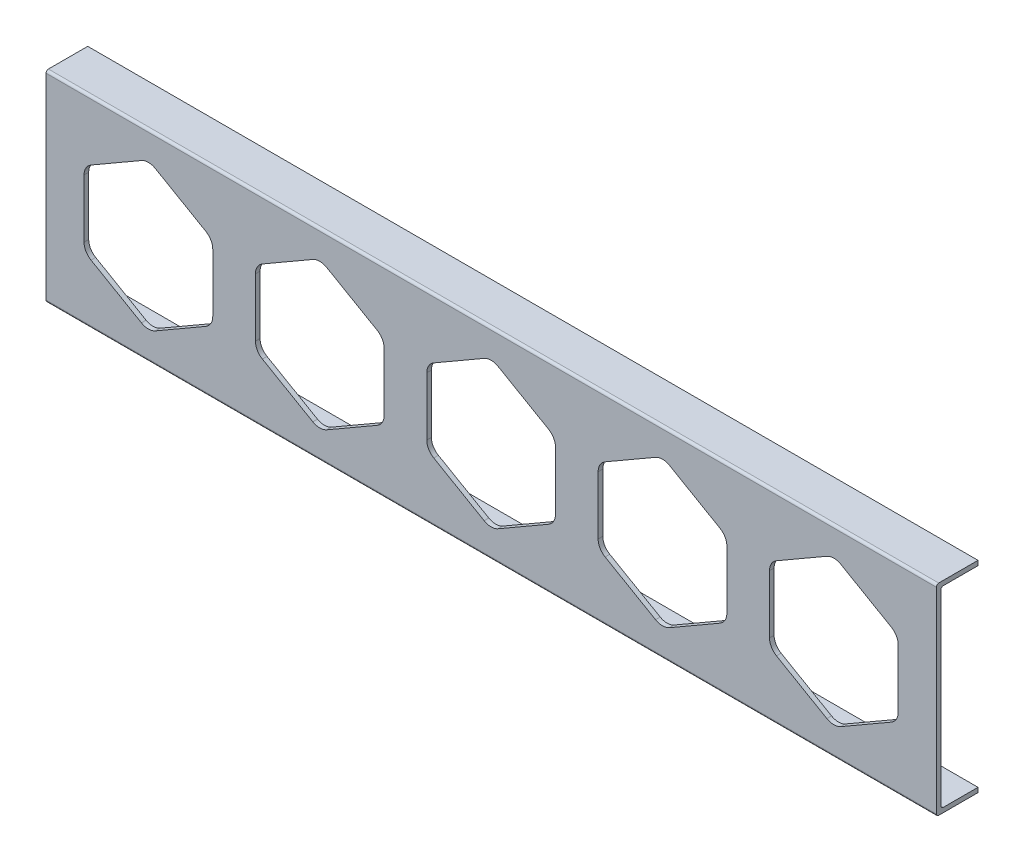
from build123d import *

# Parameters (mm, degrees)
BOSS_EXTRUDE1_DEPTH = 304.8
CUT_EXTRUDE1_REACH  = 16.288


with BuildPart() as part:
    # Sketch1 → Boss-Extrude1 (new body)
    with BuildSketch(Plane(origin=(0, 0, 0), x_dir=(0, 0, -1), z_dir=(1, 0, 0))):
        with BuildLine():
            Line((-0.762, 67.29984), (12.7, 67.29984))
            Line((12.7, 67.29984), (12.7, 65.71234))
            Line((12.7, 65.71234), (0.8255, 65.71234))
            ThreePointArc((0.8255, 65.71234), (0.241783352, 65.470556648), (0, 64.88684))
            Line((0, 64.88684), (0, 0.8255))
            ThreePointArc((0, 0.8255), (0.241783352, 0.241783352), (0.8255, 0))
            Line((0.8255, 0), (12.7, 0))
            Line((12.7, 0), (12.7, -1.5875))
            Line((12.7, -1.5875), (-0.762, -1.5875))
            ThreePointArc((-0.762, -1.5875), (-1.345716648, -1.345716648), (-1.5875, -0.762))
            Line((-1.5875, -0.762), (-1.5875, 66.47434))
            ThreePointArc((-1.5875, 66.47434), (-1.345716648, 67.058056648), (-0.762, 67.29984))
        make_face()
    extrude(amount=BOSS_EXTRUDE1_DEPTH)

    # Sketch2 → Cut-Extrude1 (cut, up to next)
    with BuildSketch(Plane.XY.offset(1.5875), mode=Mode.PRIVATE) as cut_extrude1_sk1:
        with BuildLine():
            Line((32.681340962, 56.921546337), (15.411988703, 46.951081161))
            ThreePointArc((15.411988703, 46.951081161), (13.668792717, 45.207885176), (13.030738703, 42.826635176))
            Line((13.030738703, 42.826635176), (13.030738703, 22.885704824))
            ThreePointArc((13.030738703, 22.885704824), (13.668792717, 20.504454824), (15.411988703, 18.761258839))
            Line((15.411988703, 18.761258839), (32.681340962, 8.790793663))
            ThreePointArc((32.681340962, 8.790793663), (35.062590962, 8.152739649), (37.443840962, 8.790793663))
            Line((37.443840962, 8.790793663), (54.713193222, 18.761258839))
            ThreePointArc((54.713193222, 18.761258839), (56.456389207, 20.504454824), (57.094443222, 22.885704824))
            Line((57.094443222, 22.885704824), (57.094443222, 42.826635176))
            ThreePointArc((57.094443222, 42.826635176), (56.456389207, 45.207885176), (54.713193222, 46.951081161))
            Line((54.713193222, 46.951081161), (37.443840962, 56.921546337))
            ThreePointArc((37.443840962, 56.921546337), (35.062590962, 57.559600351), (32.681340962, 56.921546337))
        make_face()
    cut_extrude1_tool1 = extrude(cut_extrude1_sk1.sketch, amount=-CUT_EXTRUDE1_REACH, mode=Mode.PRIVATE) & part.part
    add(cut_extrude1_tool1.solids().sort_by_distance((35.062591, 32.85617, 1.5875))[0], mode=Mode.SUBTRACT)
    # Sketch2 → Cut-Extrude1 (cut, up to next)
    with BuildSketch(Plane.XY.offset(1.5875), mode=Mode.PRIVATE) as cut_extrude1_sk2:
        with BuildLine():
            Line((91.350045481, 56.921546337), (74.080693222, 46.951081161))
            ThreePointArc((74.080693222, 46.951081161), (72.337497236, 45.207885176), (71.699443222, 42.826635176))
            Line((71.699443222, 42.826635176), (71.699443222, 22.885704824))
            ThreePointArc((71.699443222, 22.885704824), (72.337497236, 20.504454824), (74.080693222, 18.761258839))
            Line((74.080693222, 18.761258839), (91.350045481, 8.790793663))
            ThreePointArc((91.350045481, 8.790793663), (93.731295481, 8.152739649), (96.112545481, 8.790793663))
            Line((96.112545481, 8.790793663), (113.381897741, 18.761258839))
            ThreePointArc((113.381897741, 18.761258839), (115.125093726, 20.504454824), (115.763147741, 22.885704824))
            Line((115.763147741, 22.885704824), (115.763147741, 42.826635176))
            ThreePointArc((115.763147741, 42.826635176), (115.125093726, 45.207885176), (113.381897741, 46.951081161))
            Line((113.381897741, 46.951081161), (96.112545481, 56.921546337))
            ThreePointArc((96.112545481, 56.921546337), (93.731295481, 57.559600351), (91.350045481, 56.921546337))
        make_face()
    cut_extrude1_tool2 = extrude(cut_extrude1_sk2.sketch, amount=-CUT_EXTRUDE1_REACH, mode=Mode.PRIVATE) & part.part
    add(cut_extrude1_tool2.solids().sort_by_distance((93.731295, 32.85617, 1.5875))[0], mode=Mode.SUBTRACT)
    # Sketch2 → Cut-Extrude1 (cut, up to next)
    with BuildSketch(Plane.XY.offset(1.5875), mode=Mode.PRIVATE) as cut_extrude1_sk3:
        with BuildLine():
            Line((150.01875, 56.921546337), (132.749397741, 46.951081161))
            ThreePointArc((132.749397741, 46.951081161), (131.006201755, 45.207885176), (130.368147741, 42.826635176))
            Line((130.368147741, 42.826635176), (130.368147741, 22.885704824))
            ThreePointArc((130.368147741, 22.885704824), (131.006201755, 20.504454824), (132.749397741, 18.761258839))
            Line((132.749397741, 18.761258839), (150.01875, 8.790793663))
            ThreePointArc((150.01875, 8.790793663), (152.4, 8.152739649), (154.78125, 8.790793663))
            Line((154.78125, 8.790793663), (172.050602259, 18.761258839))
            ThreePointArc((172.050602259, 18.761258839), (173.793798245, 20.504454824), (174.431852259, 22.885704824))
            Line((174.431852259, 22.885704824), (174.431852259, 42.826635176))
            ThreePointArc((174.431852259, 42.826635176), (173.793798245, 45.207885176), (172.050602259, 46.951081161))
            Line((172.050602259, 46.951081161), (154.78125, 56.921546337))
            ThreePointArc((154.78125, 56.921546337), (152.4, 57.559600351), (150.01875, 56.921546337))
        make_face()
    cut_extrude1_tool3 = extrude(cut_extrude1_sk3.sketch, amount=-CUT_EXTRUDE1_REACH, mode=Mode.PRIVATE) & part.part
    add(cut_extrude1_tool3.solids().sort_by_distance((152.4, 32.85617, 1.5875))[0], mode=Mode.SUBTRACT)
    # Sketch2 → Cut-Extrude1 (cut, up to next)
    with BuildSketch(Plane.XY.offset(1.5875), mode=Mode.PRIVATE) as cut_extrude1_sk4:
        with BuildLine():
            Line((208.687454519, 56.921546337), (191.418102259, 46.951081161))
            ThreePointArc((191.418102259, 46.951081161), (189.674906274, 45.207885176), (189.036852259, 42.826635176))
            Line((189.036852259, 42.826635176), (189.036852259, 22.885704824))
            ThreePointArc((189.036852259, 22.885704824), (189.674906274, 20.504454824), (191.418102259, 18.761258839))
            Line((191.418102259, 18.761258839), (208.687454519, 8.790793663))
            ThreePointArc((208.687454519, 8.790793663), (211.068704519, 8.152739649), (213.449954519, 8.790793663))
            Line((213.449954519, 8.790793663), (230.719306778, 18.761258839))
            ThreePointArc((230.719306778, 18.761258839), (232.462502764, 20.504454824), (233.100556778, 22.885704824))
            Line((233.100556778, 22.885704824), (233.100556778, 42.826635176))
            ThreePointArc((233.100556778, 42.826635176), (232.462502764, 45.207885176), (230.719306778, 46.951081161))
            Line((230.719306778, 46.951081161), (213.449954519, 56.921546337))
            ThreePointArc((213.449954519, 56.921546337), (211.068704519, 57.559600351), (208.687454519, 56.921546337))
        make_face()
    cut_extrude1_tool4 = extrude(cut_extrude1_sk4.sketch, amount=-CUT_EXTRUDE1_REACH, mode=Mode.PRIVATE) & part.part
    add(cut_extrude1_tool4.solids().sort_by_distance((211.068705, 32.85617, 1.5875))[0], mode=Mode.SUBTRACT)
    # Sketch2 → Cut-Extrude1 (cut, up to next)
    with BuildSketch(Plane.XY.offset(1.5875), mode=Mode.PRIVATE) as cut_extrude1_sk5:
        with BuildLine():
            Line((267.356159038, 56.921546337), (250.086806778, 46.951081161))
            ThreePointArc((250.086806778, 46.951081161), (248.343610793, 45.207885176), (247.705556778, 42.826635176))
            Line((247.705556778, 42.826635176), (247.705556778, 22.885704824))
            ThreePointArc((247.705556778, 22.885704824), (248.343610793, 20.504454824), (250.086806778, 18.761258839))
            Line((250.086806778, 18.761258839), (267.356159038, 8.790793663))
            ThreePointArc((267.356159038, 8.790793663), (269.737409038, 8.152739649), (272.118659038, 8.790793663))
            Line((272.118659038, 8.790793663), (289.388011297, 18.761258839))
            ThreePointArc((289.388011297, 18.761258839), (291.131207283, 20.504454824), (291.769261297, 22.885704824))
            Line((291.769261297, 22.885704824), (291.769261297, 42.826635176))
            ThreePointArc((291.769261297, 42.826635176), (291.131207283, 45.207885176), (289.388011297, 46.951081161))
            Line((289.388011297, 46.951081161), (272.118659038, 56.921546337))
            ThreePointArc((272.118659038, 56.921546337), (269.737409038, 57.559600351), (267.356159038, 56.921546337))
        make_face()
    cut_extrude1_tool5 = extrude(cut_extrude1_sk5.sketch, amount=-CUT_EXTRUDE1_REACH, mode=Mode.PRIVATE) & part.part
    add(cut_extrude1_tool5.solids().sort_by_distance((269.737409, 32.85617, 1.5875))[0], mode=Mode.SUBTRACT)


solid = part.part
